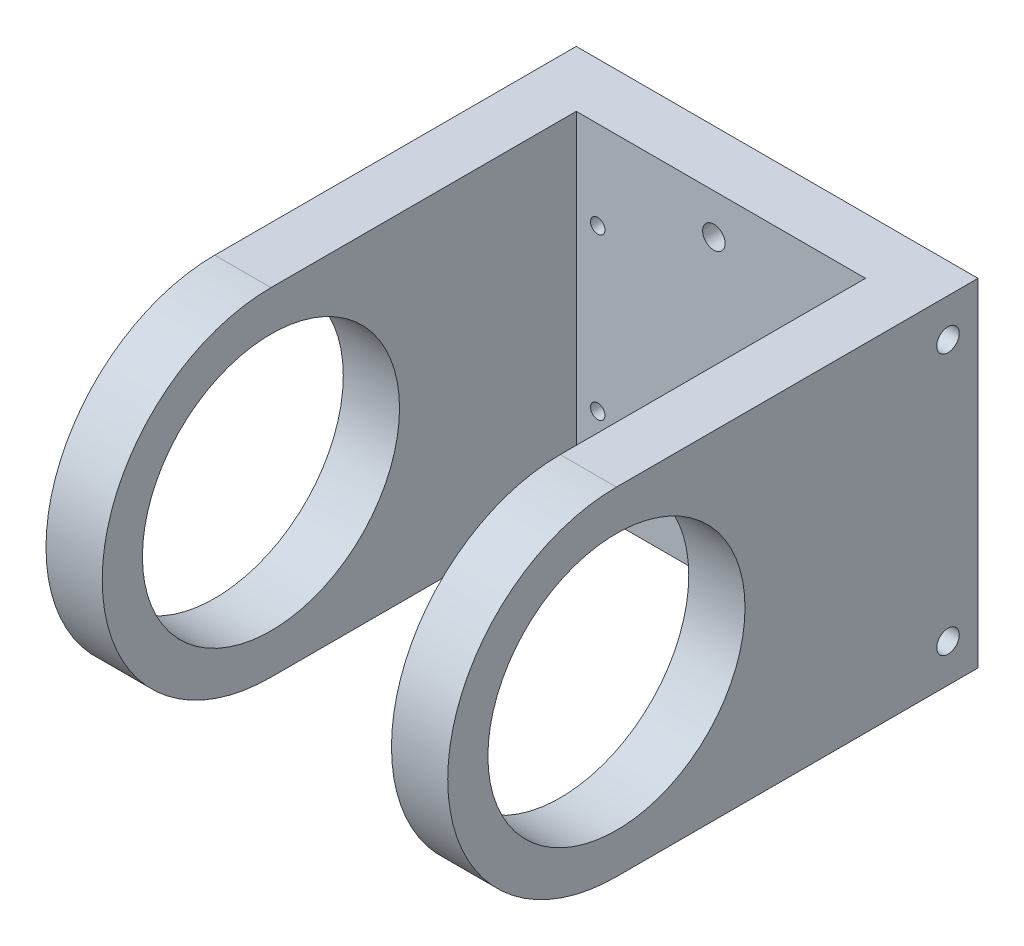
from build123d import *

# Parameters (mm, degrees)
EXTRUDE_1_DEPTH             = 50
SKETCH_2_W                  = 36
SKETCH_2_H                  = 102.163867091
CUT_EXTRUDE_1_DEPTH         = 43
HOLE_WIZARD_1_8_1_8_1_D     = 1.8
HOLE_WIZARD_1_8_1_8_1_DEPTH = 7
HOLE_WIZARD_M30_1_D         = 32
HOLE_WIZARD_M30_1_DEPTH     = 7
HOLE_WIZARD_M30_2_D         = 32
HOLE_WIZARD_M30_2_DEPTH     = 7
SKETCH_13_R                 = 1.4
CUT_EXTRUDE_2_DEPTH         = 10
SKETCH_14_R                 = 1.4
CUT_EXTRUDE_3_DEPTH         = 4


with BuildPart() as part:
    # 스케치1 → 보스-돌출1 (new body)
    with BuildSketch(Plane(origin=(-75, 0, 0), x_dir=(0, -1, 0), z_dir=(-1, 0, 0))):
        with BuildLine():
            Line((-21, 0), (-21, -45))
            Line((-21, -45), (21, -45))
            Line((21, -45), (21, 0))
            ThreePointArc((21, 0), (0, 21), (-21, 0))
        make_face()
    extrude(amount=-EXTRUDE_1_DEPTH)

    # 스케치2 → 컷-돌출1 (cut, through all)
    with BuildSketch(Plane(origin=(0, 21, 0), x_dir=(-1, 0, 0), z_dir=(0, 1, 0))):
        with Locations((50, 13.081933546)):
            Rectangle(SKETCH_2_W, SKETCH_2_H)
    extrude(amount=-CUT_EXTRUDE_1_DEPTH, mode=Mode.SUBTRACT)

    # Ø1.8 (1.8) 지름 구멍1
    with Locations(Plane(origin=(0, 0, -45), x_dir=(-1, 0, 0), z_dir=(0, 0, -1))):
        with Locations((35.3332236, 10), (65.3332236, 10), (35.3332236, -10), (65.3332236, -10)):
            Hole(HOLE_WIZARD_1_8_1_8_1_D / 2, depth=HOLE_WIZARD_1_8_1_8_1_DEPTH)

    # M30 여유 구멍1
    with Locations(Plane(origin=(-25, 0, 0), x_dir=(0, 0, -1), z_dir=(1, 0, 0))):
        with Locations((0, 0)):
            Hole(HOLE_WIZARD_M30_1_D / 2, depth=HOLE_WIZARD_M30_1_DEPTH)

    # M30 여유 구멍2
    with Locations(Plane.ZY.offset(75)):
        with Locations((0, 0)):
            Hole(HOLE_WIZARD_M30_2_D / 2, depth=HOLE_WIZARD_M30_2_DEPTH)

    # 스케치13 → 컷-돌출2 (cut)
    with BuildSketch(Plane.XY.offset(-38)):
        with Locations((-50.876817985, -16)):
            Circle(SKETCH_13_R)
        with Locations((-50.876817985, 16)):
            Circle(SKETCH_13_R)
    extrude(amount=-CUT_EXTRUDE_2_DEPTH, mode=Mode.SUBTRACT)

    # 스케치14 → 컷-돌출3 (cut)
    with BuildSketch(Plane(origin=(-25, 0, 0), x_dir=(0, 0, -1), z_dir=(1, 0, 0))):
        with Locations((41.267143481, 16.25)):
            Circle(SKETCH_14_R)
        with Locations((41.267143481, -16.25)):
            Circle(SKETCH_14_R)
    cut_extrude_3 = extrude(amount=-CUT_EXTRUDE_3_DEPTH, mode=Mode.SUBTRACT)

    # 대칭 복사1: 컷-돌출3 across plane
    add(cut_extrude_3.mirror(Plane.ZY.offset(50)), mode=Mode.SUBTRACT)


solid = part.part
